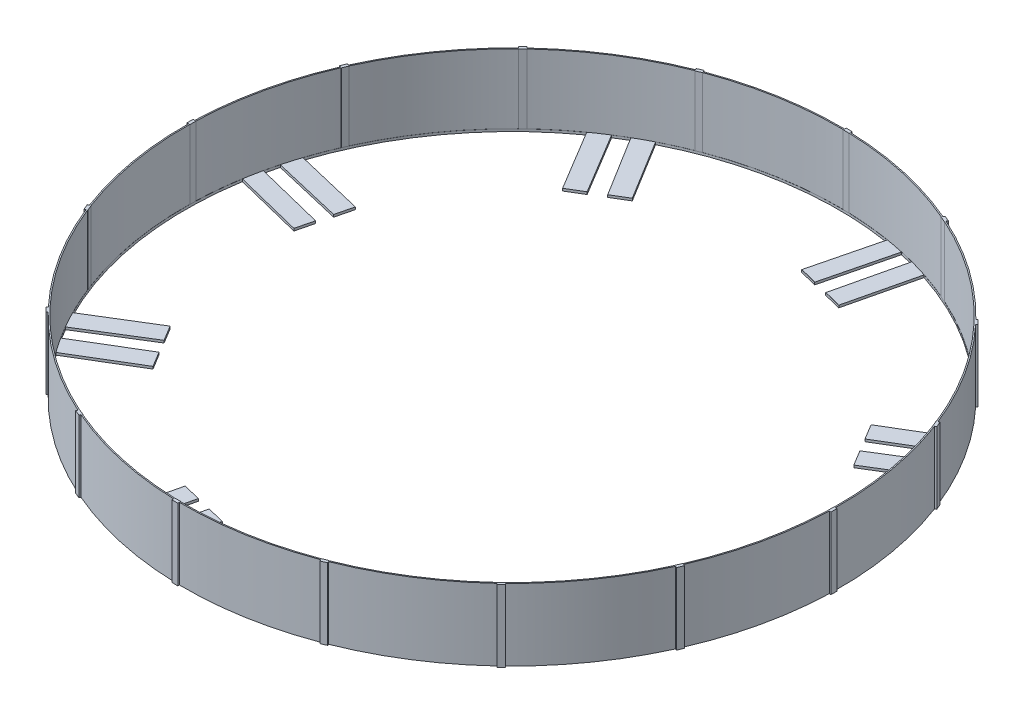
from build123d import *

# Parameters (mm, degrees)
SKETCH2_R           = 27500
BOSS_EXTRUDE1_DEPTH = 6000
SKETCH3_R           = 27400
CUT_EXTRUDE1_DEPTH  = 5800
SKETCH6_W           = 500
SKETCH6_H           = 6000
BOSS_EXTRUDE2_DEPTH = 125
CIRPATTERN1_COUNT   = 16
SKETCH8_R           = 27390
CUT_EXTRUDE2_DEPTH  = 6227
BOSS_EXTRUDE3_DEPTH = 200
CIRPATTERN2_COUNT   = 8
FILLET1_R           = 20
FILLET2_R           = 20


with BuildPart() as part:
    # Sketch2 → Boss-Extrude1 (new body)
    with BuildSketch(Plane(origin=(0, 0, 0), x_dir=(1, 0, 0), z_dir=(0, 1, 0))):
        Circle(SKETCH2_R)
    extrude(amount=BOSS_EXTRUDE1_DEPTH)

    # Sketch3 → Cut-Extrude1 (cut)
    with BuildSketch(Plane(origin=(0, 6000, 0), x_dir=(1, 0, 0), z_dir=(0, 1, 0))):
        Circle(SKETCH3_R)
    extrude(amount=-CUT_EXTRUDE1_DEPTH, mode=Mode.SUBTRACT)

    # Sketch6 → Boss-Extrude2 (add, symmetric)
    with BuildSketch(Plane(origin=(27500, 0, 0), x_dir=(0, 0, -1), z_dir=(1, 0, 0))):
        with Locations((-637.678148973, 3000)):
            Rectangle(SKETCH6_W, SKETCH6_H)
    boss_extrude2 = extrude(amount=BOSS_EXTRUDE2_DEPTH, both=True)

    # CirPattern1: Boss-Extrude2 ×16 about axis
    cirpattern1_axis = Axis((-0.099838763, 0, -0.002222088), (0, 1, 0))
    for i in range(1, CIRPATTERN1_COUNT):
        add(boss_extrude2.rotate(cirpattern1_axis, i * 360 / CIRPATTERN1_COUNT))

    # Sketch8 → Cut-Extrude2 (cut)
    with BuildSketch(Plane(origin=(0, 200, 0), x_dir=(1, 0, 0), z_dir=(0, 1, 0))):
        Circle(SKETCH8_R)
    extrude(amount=-CUT_EXTRUDE2_DEPTH, mode=Mode.SUBTRACT)

    # Sketch10 → Boss-Extrude3 (add)
    with BuildSketch(Plane(origin=(0, 0, 0), x_dir=(1, 0, 0), z_dir=(0, 1, 0))):
        Polygon((5674.449471115, 20624.936870229), (7130.593663822, 20264.875639263), (8525.890485748, 26100.35051109), (7045.930869189, 26466.087336938), align=None)
        Polygon((4448.034501077, 27106.711485076), (5904.408113757, 26747.579336294), (4455.093983876, 20925.206988902), (2998.73097018, 21284.382116574), align=None)
    boss_extrude3 = extrude(amount=BOSS_EXTRUDE3_DEPTH)

    # CirPattern2: Boss-Extrude3 ×8 about axis
    cirpattern2_axis = Axis((0, 0, 0), (0, 1, 0))
    for i in range(1, CIRPATTERN2_COUNT):
        add(boss_extrude3.rotate(cirpattern2_axis, i * 360 / CIRPATTERN2_COUNT))

    # Fillet1
    fillet1_edges = [part.edges().sort_by_distance(p)[0] for p in [
        (3726.912477028, 200, -21104.794552738),
    ]]
    fillet(fillet1_edges, radius=FILLET1_R)

    # Fillet2
    fillet2_edges = [part.edges().sort_by_distance(p)[0] for p in [
        (6402.521567469, 200, -20444.906254746),
    ]]
    fillet(fillet2_edges, radius=FILLET2_R)


solid = part.part
